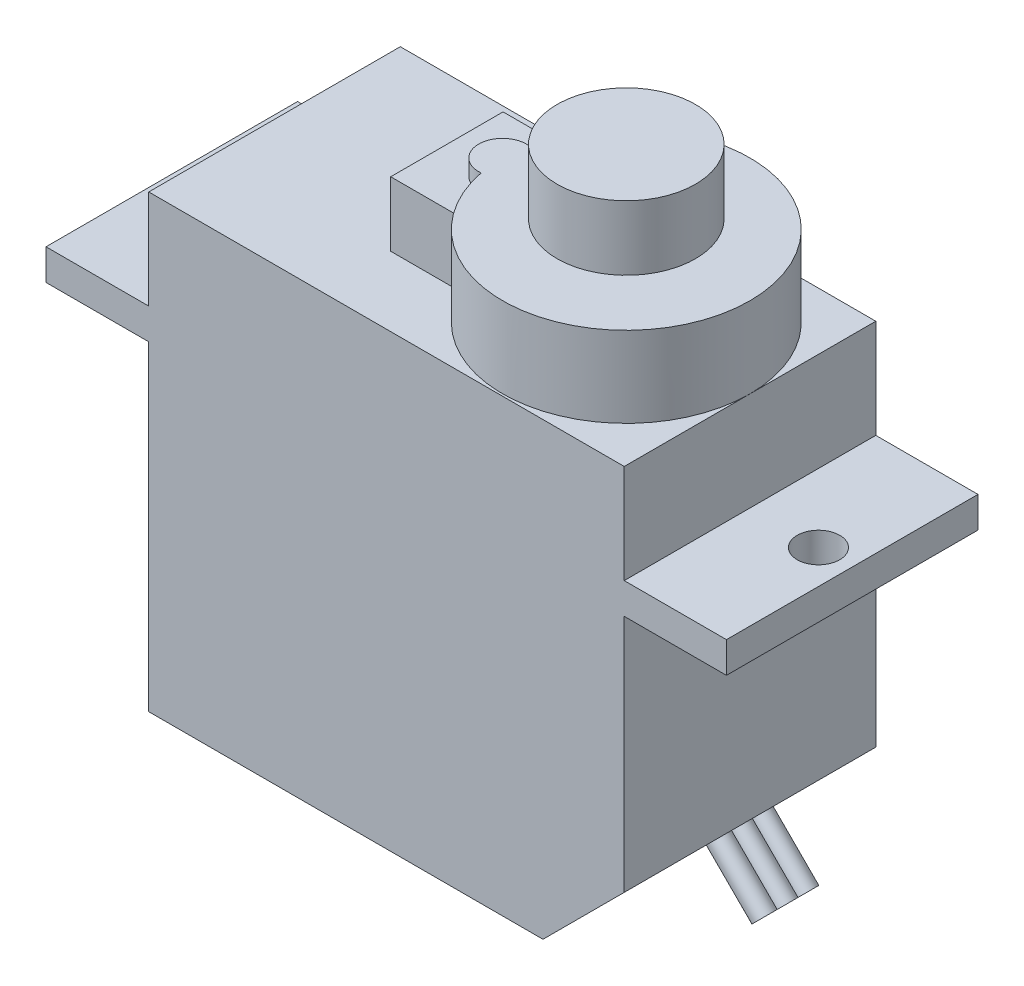
from build123d import *

# Parameters (mm, degrees)
BOSS_EXTRUDE1_DEPTH     = 12.2
SKETCH4_W               = 33
SKETCH4_H               = 1.5
BOSS_EXTRUDE2_DEPTH     = 12.2
SKETCH6_R               = 1.03
CUT_EXTRUDE1_DEPTH      = 5.83
CUT_EXTRUDE1_DEPTH_BACK = 18
SKETCH7_R               = 1.03
CUT_EXTRUDE2_DEPTH      = 5.83
CUT_EXTRUDE2_DEPTH_BACK = 18
SKETCH9_R               = 6
BOSS_EXTRUDE3_DEPTH     = 8.74
SKETCH11_R              = 1.16
BOSS_EXTRUDE4_DEPTH     = 8.74
SKETCH13_W              = 5.4
SKETCH13_H              = 5.45
BOSS_EXTRUDE5_DEPTH     = 7.96
SKETCH14_R              = 2.345
BOSS_EXTRUDE6_DEPTH     = 11.51
SKETCH15_R              = 0.635
CUT_EXTRUDE3_DEPTH      = 3.13
BOSS_EXTRUDE7_START     = 0.8
SKETCH17_R              = 3.355
BOSS_EXTRUDE7_DEPTH     = 3.13
SKETCH18_R              = 0.5
BOSS_EXTRUDE8_DEPTH     = 3.13


with BuildPart() as part:
    # Sketch1 → Boss-Extrude1 (new body)
    with BuildSketch(Plane.XY):
        Polygon((19.12, 0), (23.06, 3.94), (23.06, 21.83), (0, 21.83), (0, 0), align=None)
    extrude(amount=-BOSS_EXTRUDE1_DEPTH)



with BuildPart() as body_2:
    # Sketch4 → Boss-Extrude2 (new body)
    with BuildSketch(Plane.XY):
        with Locations((11.517097498, 16.2852801)):
            Rectangle(SKETCH4_W, SKETCH4_H)
    extrude(amount=-BOSS_EXTRUDE2_DEPTH)

    # Sketch6 → Cut-Extrude1 (cut, two sides)
    with BuildSketch(Plane(origin=(0, 17, 0), x_dir=(1, 0, 0), z_dir=(0, 1, 0))) as cut_extrude1_sk:
        with Locations((-3.31, 6.1)):
            Circle(SKETCH6_R)
    extrude(amount=CUT_EXTRUDE1_DEPTH, mode=Mode.SUBTRACT)
    extrude(cut_extrude1_sk.sketch, amount=-CUT_EXTRUDE1_DEPTH_BACK, mode=Mode.SUBTRACT)

    # Sketch7 → Cut-Extrude2 (cut, two sides)
    with BuildSketch(Plane(origin=(0, 17, 0), x_dir=(1, 0, 0), z_dir=(0, 1, 0))) as cut_extrude2_sk:
        with Locations((26.38, 6.1)):
            Circle(SKETCH7_R)
    extrude(amount=CUT_EXTRUDE2_DEPTH, mode=Mode.SUBTRACT)
    extrude(cut_extrude2_sk.sketch, amount=-CUT_EXTRUDE2_DEPTH_BACK, mode=Mode.SUBTRACT)


with BuildPart() as part_1:
    add(part.part)

    add(body_2.part)  # Boss-Extrude3 merges body 2
    # Sketch9 → Boss-Extrude3 (add)
    with BuildSketch(Plane(origin=(0, 17, 0), x_dir=(1, 0, 0), z_dir=(0, 1, 0))):
        with Locations((17.06, 6.1)):
            Circle(SKETCH9_R)
    extrude(amount=BOSS_EXTRUDE3_DEPTH)

    # Sketch11 → Boss-Extrude4 (add)
    with BuildSketch(Plane(origin=(0, 17, 0), x_dir=(1, 0, 0), z_dir=(0, 1, 0))):
        with Locations((11.06, 6.1)):
            Circle(SKETCH11_R)
    extrude(amount=BOSS_EXTRUDE4_DEPTH)

    # Sketch13 → Boss-Extrude5 (add)
    with BuildSketch(Plane(origin=(0, 17, 0), x_dir=(1, 0, 0), z_dir=(0, 1, 0))):
        with Locations((11.06, 6.1)):
            Rectangle(SKETCH13_W, SKETCH13_H)
    extrude(amount=BOSS_EXTRUDE5_DEPTH)

    # Sketch14 → Boss-Extrude6 (add)
    with BuildSketch(Plane(origin=(0, 17, 0), x_dir=(1, 0, 0), z_dir=(0, 1, 0))):
        with Locations((17.06, 6.1)):
            Circle(SKETCH14_R)
    extrude(amount=BOSS_EXTRUDE6_DEPTH)

    # Sketch15 → Cut-Extrude3 (cut)
    with BuildSketch(Plane(origin=(0, 28.51, 0), x_dir=(1, 0, 0), z_dir=(0, 1, 0))):
        with Locations((17.06, 6.1)):
            Circle(SKETCH15_R)
    extrude(amount=-CUT_EXTRUDE3_DEPTH, mode=Mode.SUBTRACT)

    # Sketch17 → Boss-Extrude7 (add)
    with BuildSketch(Plane(origin=(0, 28.51, 0), x_dir=(1, 0, 0), z_dir=(0, 1, 0)).offset(BOSS_EXTRUDE7_START)):
        with Locations((17.06, 6.1)):
            Circle(SKETCH17_R)
    extrude(amount=-BOSS_EXTRUDE7_DEPTH)

    # Sketch18 → Boss-Extrude8 (add)
    with BuildSketch(Plane(origin=(9.56, -9.56, 0), x_dir=(0, 0, -1), z_dir=(0.707106781, -0.707106781, 0))):
        with Locations((5.09, 18.386997448)):
            Circle(SKETCH18_R)
        with Locations((6.1, 18.386997448)):
            Circle(SKETCH18_R)
        with Locations((7.11, 18.386997448)):
            Circle(SKETCH18_R)
    extrude(amount=BOSS_EXTRUDE8_DEPTH)


solid = part_1.part
